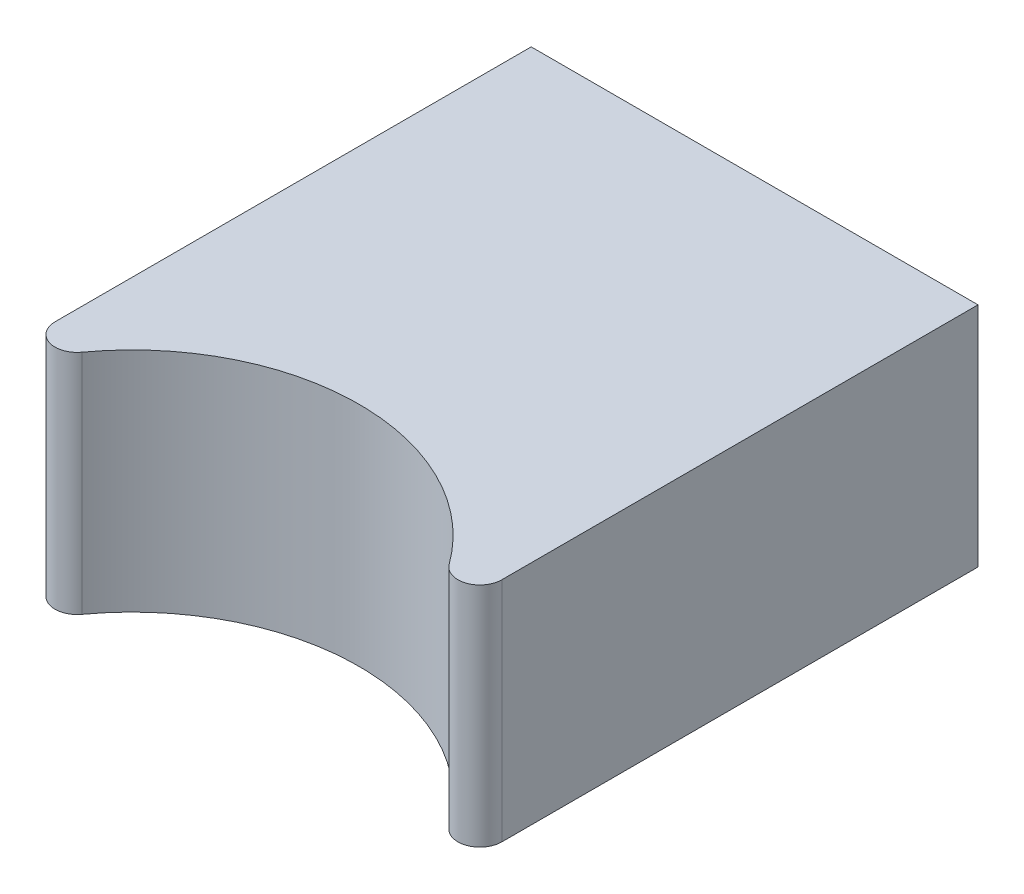
from build123d import *

# Parameters (mm, degrees)
SKETCH1_W           = 6.1
SKETCH1_H           = 5.4
BOSS_EXTRUDE2_DEPTH = 3.1
FILLET1_R           = 0.3


with BuildPart() as part:
    # Sketch1 → Boss-Extrude2 (new body)
    with BuildSketch(Plane(origin=(0, 0, 0), x_dir=(1, 0, 0), z_dir=(0, 1, 0))):
        Rectangle(SKETCH1_W, SKETCH1_H)
        with BuildLine():
            Line((0, -2.7), (-3.05, -2.7))
            Line((-3.05, -2.7), (-3.05, -5.245473175))
            ThreePointArc((-3.05, -5.245473175), (-1.986324098, -3.419975509), (0, -2.7))
        make_face()
        with BuildLine():
            Line((3.05, -2.7), (0, -2.7))
            ThreePointArc((0, -2.7), (1.986324098, -3.419975509), (3.05, -5.245473175))
            Line((3.05, -5.245473175), (3.05, -2.7))
        make_face()
    extrude(amount=BOSS_EXTRUDE2_DEPTH)

    # Fillet1
    fillet1_edges = [part.edges().sort_by_distance(p)[0] for p in [
        (3.05, 1.55, 5.245473175),
        (-3.05, 1.55, 5.245473175),
    ]]
    fillet(fillet1_edges, radius=FILLET1_R)


solid = part.part
